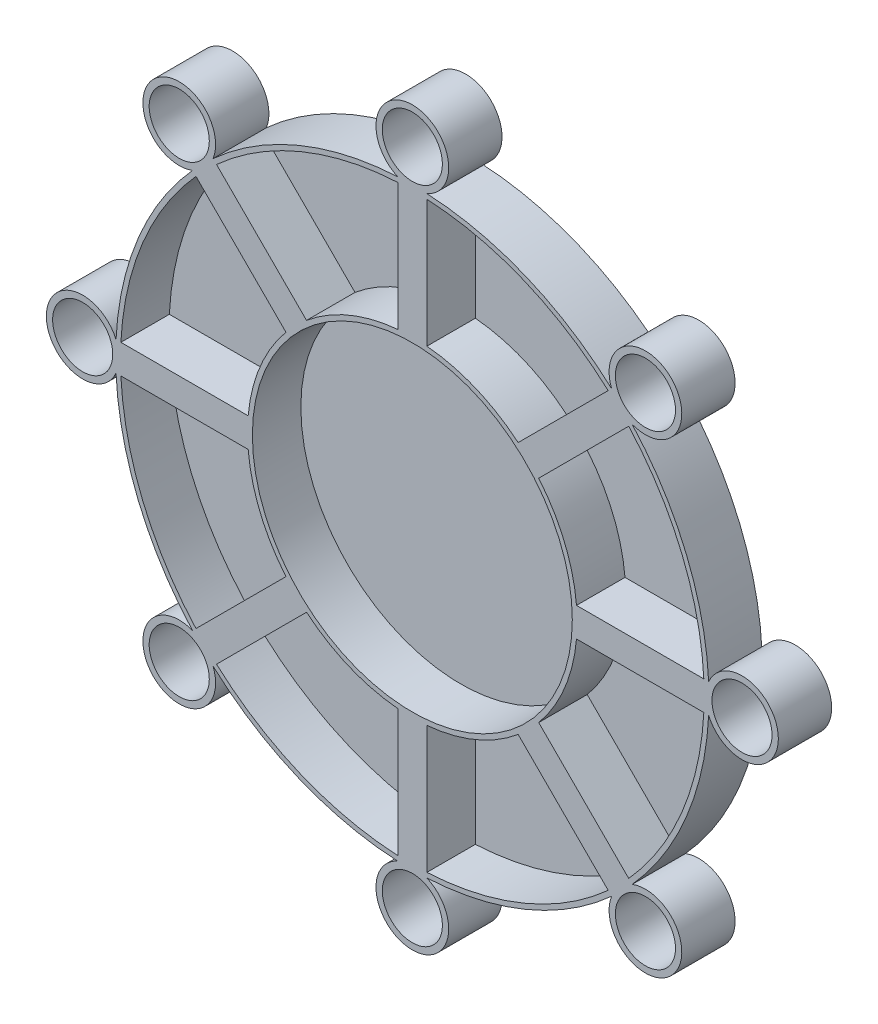
from build123d import *

# Parameters (mm, degrees)
SALIENTE_EXTRUIR1_DEPTH = 11
CROQUIS2_R              = 33
CROQUIS2_R_2            = 6.2
CORTAR_EXTRUIR1_DEPTH   = 10
SALIENTE_EXTRUIR2_DEPTH = 1
SALIENTE_EXTRUIR3_DEPTH = 10


with BuildPart() as part:
    # Croquis1 → Saliente-Extruir1 (new body)
    with BuildSketch(Plane.XY):
        with BuildLine():
            Line((-39.705480667, 55.513594064), (-58.980326234, 36.238748497))
            ThreePointArc((-58.980326234, 36.238748497), (-67.79562922, 41.581472229), (-77.806865921, 44.036956568))
            Line((-77.806865921, 44.036956568), (-77.806865921, 71.295704582))
            ThreePointArc((-77.806865921, 71.295704582), (-80.806865921, 85.669568124), (-83.806865921, 71.295704582))
            Line((-83.806865921, 71.295704582), (-83.806865921, 44.036956568))
            ThreePointArc((-83.806865921, 44.036956568), (-93.818102621, 41.581472229), (-102.633405607, 36.238748497))
            Line((-102.633405607, 36.238748497), (-121.908251174, 55.513594064))
            ThreePointArc((-121.908251174, 55.513594064), (-134.1934279, 63.556130104), (-126.150891861, 51.270953377))
            Line((-126.150891861, 51.270953377), (-106.876046294, 31.99610781))
            ThreePointArc((-106.876046294, 31.99610781), (-112.218770026, 23.180804824), (-114.674254364, 13.169568124))
            Line((-114.674254364, 13.169568124), (-141.933002378, 13.169568124))
            ThreePointArc((-141.933002378, 13.169568124), (-156.306865921, 10.169568124), (-141.933002378, 7.169568124))
            Line((-141.933002378, 7.169568124), (-114.674254364, 7.169568124))
            ThreePointArc((-114.674254364, 7.169568124), (-112.218770026, -2.841668576), (-106.876046294, -11.656971562))
            Line((-106.876046294, -11.656971562), (-126.150891861, -30.931817129))
            ThreePointArc((-126.150891861, -30.931817129), (-134.1934279, -43.216993856), (-121.908251174, -35.174457817))
            Line((-121.908251174, -35.174457817), (-102.633405607, -15.899612249))
            ThreePointArc((-102.633405607, -15.899612249), (-93.818102621, -21.242335981), (-83.806865921, -23.69782032))
            Line((-83.806865921, -23.69782032), (-83.806865921, -50.956568334))
            ThreePointArc((-83.806865921, -50.956568334), (-80.806865921, -65.330431876), (-77.806865921, -50.956568334))
            Line((-77.806865921, -50.956568334), (-77.806865921, -23.69782032))
            ThreePointArc((-77.806865921, -23.69782032), (-67.79562922, -21.242335981), (-58.980326234, -15.899612249))
            Line((-58.980326234, -15.899612249), (-39.705480667, -35.174457816))
            ThreePointArc((-39.705480667, -35.174457816), (-27.420303941, -43.216993856), (-35.46283998, -30.931817129))
            Line((-35.46283998, -30.931817129), (-54.737685547, -11.656971562))
            ThreePointArc((-54.737685547, -11.656971562), (-49.394961815, -2.841668576), (-46.939477477, 7.169568124))
            Line((-46.939477477, 7.169568124), (-19.680729463, 7.169568124))
            ThreePointArc((-19.680729463, 7.169568124), (-5.306865921, 10.169568124), (-19.680729463, 13.169568124))
            Line((-19.680729463, 13.169568124), (-46.939477477, 13.169568124))
            ThreePointArc((-46.939477477, 13.169568124), (-49.394961815, 23.180804824), (-54.737685547, 31.99610781))
            Line((-54.737685547, 31.99610781), (-35.46283998, 51.270953377))
            ThreePointArc((-35.46283998, 51.270953377), (-27.420303941, 63.556130104), (-39.705480667, 55.513594064))
        make_face()
    extrude(amount=SALIENTE_EXTRUIR1_DEPTH)

    # Croquis2 → Cortar-Extruir1 (cut)
    with BuildSketch(Plane.XY.offset(11)):
        with Locations((-80.806865921, 10.169568124)):
            Circle(CROQUIS2_R)
        with Locations((-128.890127041, 58.252829245)):
            Circle(CROQUIS2_R_2)
        with Locations((-80.806865921, 78.169568124)):
            Circle(CROQUIS2_R_2)
        with Locations((-32.7236048, 58.252829245)):
            Circle(CROQUIS2_R_2)
        with Locations((-12.806865921, 10.169568124)):
            Circle(CROQUIS2_R_2)
        with Locations((-32.7236048, -37.913692997)):
            Circle(CROQUIS2_R_2)
        with Locations((-80.806865921, -57.830431876)):
            Circle(CROQUIS2_R_2)
        with Locations((-128.890127041, -37.913692997)):
            Circle(CROQUIS2_R_2)
        with Locations((-148.806865921, 10.169568124)):
            Circle(CROQUIS2_R_2)
    extrude(amount=-CORTAR_EXTRUIR1_DEPTH, mode=Mode.SUBTRACT)

    # Croquis3 → Saliente-Extruir2 (add)
    with BuildSketch(Plane(origin=(0, 0, 0), x_dir=(-1, 0, 0), z_dir=(0, 0, -1))):
        with BuildLine():
            Line((114.674254364, 7.169568124), (141.933002378, 7.169568124))
            ThreePointArc((141.933002378, 7.169568124), (137.348025794, -13.250547128), (126.150891861, -30.931817129))
            Line((126.150891861, -30.931817129), (106.876046294, -11.656971562))
            ThreePointArc((106.876046294, -11.656971562), (112.218770026, -2.841668576), (114.674254364, 7.169568124))
        make_face()
        with BuildLine():
            Line((102.633405607, -15.899612249), (121.908251174, -35.174457816))
            ThreePointArc((121.908251174, -35.174457816), (104.226981172, -46.371591749), (83.806865921, -50.956568334))
            Line((83.806865921, -50.956568334), (83.806865921, -23.69782032))
            ThreePointArc((83.806865921, -23.69782032), (93.818102621, -21.242335981), (102.633405607, -15.899612249))
        make_face()
        with BuildLine():
            Line((77.806865921, -23.69782032), (77.806865921, -50.956568334))
            ThreePointArc((77.806865921, -50.956568334), (57.386750669, -46.371591749), (39.705480667, -35.174457816))
            Line((39.705480667, -35.174457816), (58.980326234, -15.899612249))
            ThreePointArc((58.980326234, -15.899612249), (67.79562922, -21.242335981), (77.806865921, -23.69782032))
        make_face()
        with BuildLine():
            Line((54.737685547, -11.656971562), (35.46283998, -30.931817129))
            ThreePointArc((35.46283998, -30.931817129), (24.265706047, -13.250547128), (19.680729463, 7.169568124))
            Line((19.680729463, 7.169568124), (46.939477477, 7.169568124))
            ThreePointArc((46.939477477, 7.169568124), (49.394961815, -2.841668576), (54.737685547, -11.656971562))
        make_face()
        with BuildLine():
            Line((46.939477477, 13.169568124), (19.680729463, 13.169568124))
            ThreePointArc((19.680729463, 13.169568124), (24.265706047, 33.589683376), (35.46283998, 51.270953377))
            Line((35.46283998, 51.270953377), (54.737685547, 31.99610781))
            ThreePointArc((54.737685547, 31.99610781), (49.394961815, 23.180804824), (46.939477477, 13.169568124))
        make_face()
        with BuildLine():
            Line((58.980326234, 36.238748497), (39.705480667, 55.513594064))
            ThreePointArc((39.705480667, 55.513594064), (57.386750669, 66.710727997), (77.806865921, 71.295704581))
            Line((77.806865921, 71.295704581), (77.806865921, 44.036956568))
            ThreePointArc((77.806865921, 44.036956568), (67.79562922, 41.581472229), (58.980326234, 36.238748497))
        make_face()
        with BuildLine():
            Line((83.806865921, 44.036956568), (83.806865921, 71.295704581))
            ThreePointArc((83.806865921, 71.295704581), (104.226981172, 66.710727997), (121.908251174, 55.513594064))
            Line((121.908251174, 55.513594064), (102.633405607, 36.238748497))
            ThreePointArc((102.633405607, 36.238748497), (93.818102621, 41.581472229), (83.806865921, 44.036956568))
        make_face()
        with BuildLine():
            Line((106.876046294, 31.99610781), (126.150891861, 51.270953377))
            ThreePointArc((126.150891861, 51.270953377), (137.348025794, 33.589683376), (141.933002378, 13.169568124))
            Line((141.933002378, 13.169568124), (114.674254364, 13.169568124))
            ThreePointArc((114.674254364, 13.169568124), (112.218770026, 23.180804824), (106.876046294, 31.99610781))
        make_face()
    extrude(amount=-SALIENTE_EXTRUIR2_DEPTH)

    # Croquis4 → Saliente-Extruir3 (add)
    with BuildSketch(Plane.XY.offset(1)):
        with BuildLine():
            Line((-126.150891861, -30.931817129), (-125.44378508, -30.224710348))
            ThreePointArc((-125.44378508, -30.224710348), (-136.425275383, -12.868331393), (-140.933002378, 7.169568124))
            Line((-140.933002378, 7.169568124), (-141.933002378, 7.169568124))
            ThreePointArc((-141.933002378, 7.169568124), (-137.348025794, -13.250547128), (-126.150891861, -30.931817129))
        make_face()
        with BuildLine():
            Line((-141.933002378, 13.169568124), (-140.933002378, 13.169568124))
            ThreePointArc((-140.933002378, 13.169568124), (-136.425275383, 33.207467641), (-125.44378508, 50.563846596))
            Line((-125.44378508, 50.563846596), (-126.150891861, 51.270953377))
            ThreePointArc((-126.150891861, 51.270953377), (-137.348025794, 33.589683376), (-141.933002378, 13.169568124))
        make_face()
        with BuildLine():
            Line((-121.908251174, 55.513594064), (-121.201144393, 54.806487283))
            ThreePointArc((-121.201144393, 54.806487283), (-103.844765438, 65.787977587), (-83.806865921, 70.295704581))
            Line((-83.806865921, 70.295704581), (-83.806865921, 71.295704581))
            ThreePointArc((-83.806865921, 71.295704581), (-104.226981172, 66.710727997), (-121.908251174, 55.513594064))
        make_face()
        with BuildLine():
            Line((-77.806865921, 71.295704581), (-77.806865921, 70.295704581))
            ThreePointArc((-77.806865921, 70.295704581), (-57.768966404, 65.787977587), (-40.412587448, 54.806487283))
            Line((-40.412587448, 54.806487283), (-39.705480667, 55.513594064))
            ThreePointArc((-39.705480667, 55.513594064), (-57.386750669, 66.710727997), (-77.806865921, 71.295704581))
        make_face()
        with BuildLine():
            Line((-35.46283998, 51.270953377), (-36.169946761, 50.563846596))
            ThreePointArc((-36.169946761, 50.563846596), (-25.188456458, 33.207467641), (-20.680729463, 13.169568124))
            Line((-20.680729463, 13.169568124), (-19.680729463, 13.169568124))
            ThreePointArc((-19.680729463, 13.169568124), (-24.265706047, 33.589683376), (-35.46283998, 51.270953377))
        make_face()
        with BuildLine():
            Line((-19.680729463, 7.169568124), (-20.680729463, 7.169568124))
            ThreePointArc((-20.680729463, 7.169568124), (-25.188456458, -12.868331393), (-36.169946761, -30.224710348))
            Line((-36.169946761, -30.224710348), (-35.46283998, -30.931817129))
            ThreePointArc((-35.46283998, -30.931817129), (-24.265706047, -13.250547128), (-19.680729463, 7.169568124))
        make_face()
        with BuildLine():
            Line((-39.705480667, -35.174457816), (-40.412587448, -34.467351035))
            ThreePointArc((-40.412587448, -34.467351035), (-57.768966404, -45.448841339), (-77.806865921, -49.956568334))
            Line((-77.806865921, -49.956568334), (-77.806865921, -50.956568334))
            ThreePointArc((-77.806865921, -50.956568334), (-57.386750669, -46.371591749), (-39.705480667, -35.174457816))
        make_face()
        with BuildLine():
            Line((-83.806865921, -50.956568334), (-83.806865921, -49.956568334))
            ThreePointArc((-83.806865921, -49.956568334), (-103.844765438, -45.448841339), (-121.201144393, -34.467351035))
            Line((-121.201144393, -34.467351035), (-121.908251174, -35.174457816))
            ThreePointArc((-121.908251174, -35.174457816), (-104.226981172, -46.371591749), (-83.806865921, -50.956568334))
        make_face()
    extrude(amount=SALIENTE_EXTRUIR3_DEPTH)


solid = part.part
